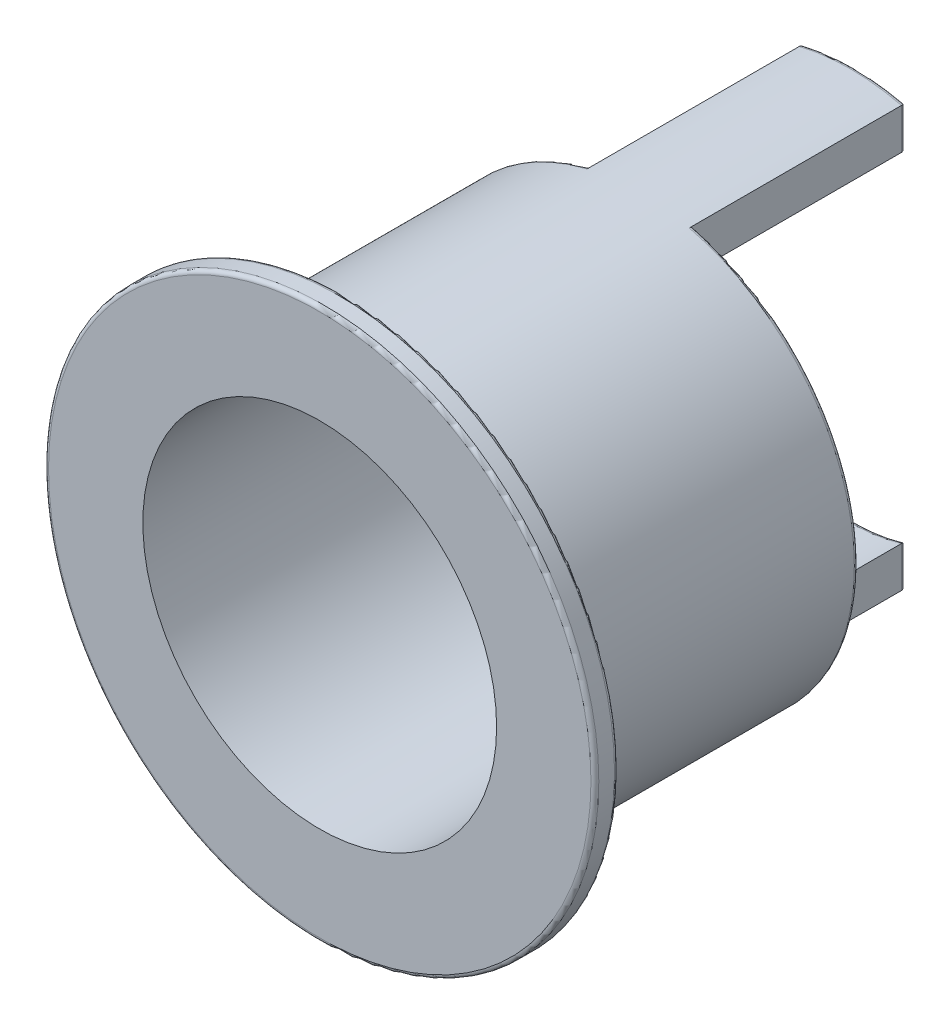
from build123d import *

# Parameters (mm, degrees)
SKETCH_1_R          = 3.5
SKETCH_1_R_2        = 2.75
SKETCH_1_R_3        = 2.25
EXTRUDE_1_DEPTH     = 0.3
SKETCH_1_4_R        = 2.75
SKETCH_1_4_R_2      = 2.25
EXTRUDE_2_DEPTH     = 6.5
CUT_EXTRUDE_1_DEPTH = 2.7
FILLET_1_R          = 0.05


with BuildPart() as part:
    # Sketch 1 → Extrude 1 (new body)
    with BuildSketch(Plane.XY):
        Circle(SKETCH_1_R)
        Circle(SKETCH_1_R_2, mode=Mode.SUBTRACT)
        Circle(SKETCH_1_R_2)
        Circle(SKETCH_1_R_3, mode=Mode.SUBTRACT)
    extrude(amount=EXTRUDE_1_DEPTH)

    # Sketch 1_4 → Extrude 2 (add)
    with BuildSketch(Plane.XY):
        Circle(SKETCH_1_4_R)
        Circle(SKETCH_1_4_R_2, mode=Mode.SUBTRACT)
    extrude(amount=-EXTRUDE_2_DEPTH)

    # Sketch 2 → Cut-Extrude 1 (cut)
    with BuildSketch(Plane(origin=(0, 0, -6.5), x_dir=(-1, 0, 0), z_dir=(0, 0, -1))):
        with BuildLine():
            ThreePointArc((-0.65, 2.672077843), (-2.75, 0), (-0.65, -2.672077843))
            Line((-0.65, -2.672077843), (-0.65, -2.154065923))
            ThreePointArc((-0.65, -2.154065923), (-2.25, 0), (-0.65, 2.154065923))
            Line((-0.65, 2.154065923), (-0.65, 2.672077843))
        make_face()
        with BuildLine():
            Line((0.65, -2.154065923), (0.65, -2.672077843))
            ThreePointArc((0.65, -2.672077843), (2.162174831, -1.699264547), (2.75, 0))
            ThreePointArc((2.75, 0), (2.162174831, 1.699264547), (0.65, 2.672077843))
            Line((0.65, 2.672077843), (0.65, 2.154065923))
            ThreePointArc((0.65, 2.154065923), (1.806239187, 1.341640786), (2.25, 0))
            ThreePointArc((2.25, 0), (1.806239187, -1.341640786), (0.65, -2.154065923))
        make_face()
    extrude(amount=-CUT_EXTRUDE_1_DEPTH, mode=Mode.SUBTRACT)

    # Fillet 1
    fillet_1_edges = [part.edges().sort_by_distance(p)[0] for p in [
        (2.162174831, -1.699264547, -3.8),
        (0.65, -2.413071883, -6.5),
        (0.65, 2.413071883, -6.5),
        (0, -2.75, -6.5),
        (0, -2.25, -6.5),
        (-0.65, -2.413071883, -6.5),
        (-0.65, 2.413071883, -6.5),
        (-2.75, 0, -3.8),
        (-3.5, 0, 0),
        (-3.5, 0, 0.3),
        (0, 2.75, -6.5),
        (0, 2.25, -6.5),
    ]]
    fillet(fillet_1_edges, radius=FILLET_1_R)


solid = part.part
